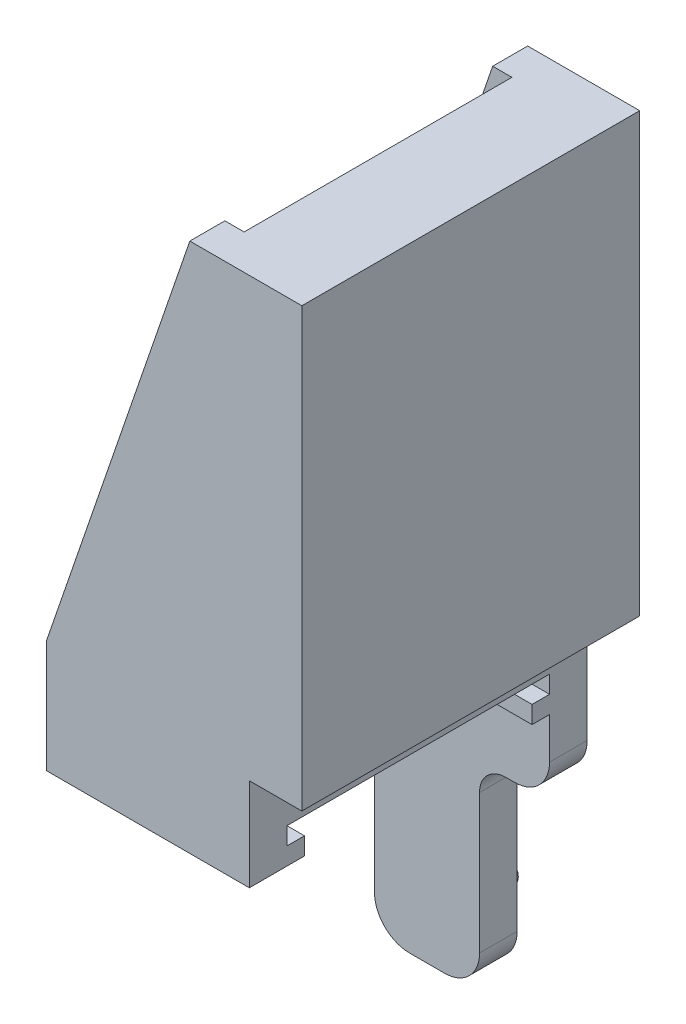
from build123d import *

# Parameters (mm, degrees)
SALIENTE_EXTRUIR1_DEPTH = 19.3
CROQUIS2_W              = 15.3
CROQUIS2_H              = 26.3
CORTAR_EXTRUIR1_DEPTH   = 9.3
CORTAR_EXTRUIR2_DEPTH   = 12
CROQUIS5_R              = 0.75
SALIENTE_EXTRUIR2_DEPTH = 2
CROQUIS6_W              = 19.3
CROQUIS6_H              = 25
SALIENTE_EXTRUIR3_DEPTH = 3


with BuildPart() as part:
    # Croquis1 → Saliente-Extruir1 (new body)
    with BuildSketch(Plane.XY):
        with BuildLine():
            Line((5.8, 23.05), (2.4, 23.05))
            Line((2.4, 23.05), (-5.8, -0.85))
            Line((-5.8, -0.85), (-5.8, -10.609737321))
            ThreePointArc((-5.8, -10.609737321), (-5.505459406, -11.318487649), (-4.795345946, -11.609726491))
            Line((-4.795345946, -11.609726491), (-4.702327027, -11.609293571))
            ThreePointArc((-4.702327027, -11.609293571), (-4.347270297, -11.754912992), (-4.2, -12.109288156))
            Line((-4.2, -12.109288156), (-4.2, -21.05))
            ThreePointArc((-4.2, -21.05), (-3.614213562, -22.464213562), (-2.2, -23.05))
            Line((-2.2, -23.05), (-0.2, -23.05))
            ThreePointArc((-0.2, -23.05), (1.214213562, -22.464213562), (1.8, -21.05))
            Line((1.8, -21.05), (1.8, -13.106955688))
            ThreePointArc((1.8, -13.106955688), (2.239339828, -12.046295517), (3.3, -11.606955688))
            Line((3.3, -11.606955688), (3.8, -11.606955688))
            ThreePointArc((3.8, -11.606955688), (5.214213562, -11.021169251), (5.8, -9.606955688))
            Line((5.8, -9.606955688), (5.8, 23.05))
        make_face()
    extrude(amount=SALIENTE_EXTRUIR1_DEPTH)

    # Croquis2 → Cortar-Extruir1 (cut)
    with BuildSketch(Plane.ZY.offset(5.8)):
        with Locations((9.65, 9.9)):
            Rectangle(CROQUIS2_W, CROQUIS2_H)
    extrude(amount=-CORTAR_EXTRUIR1_DEPTH, mode=Mode.SUBTRACT)

    # Croquis4 → Cortar-Extruir2 (cut)
    with BuildSketch(Plane.ZY.offset(5.8)):
        Polygon((2.15, -5.25), (2.15, -6.25), (3.15, -6.25), (3.15, -7.25), (2.15, -7.25), (2.15, -23.25), (19.55, -23.25), (19.55, -7.25), (16.15, -7.25), (16.15, -6.25), (17.15, -6.25), (17.15, -5.25), align=None)
    extrude(amount=-CORTAR_EXTRUIR2_DEPTH, mode=Mode.SUBTRACT)

    # Croquis5 → Saliente-Extruir2 (add)
    with BuildSketch(Plane(origin=(0, 0, 0), x_dir=(-1, 0, 0), z_dir=(0, 0, -1))):
        with Locations((0.885806677, -20.318206006)):
            Circle(CROQUIS5_R)
    extrude(amount=SALIENTE_EXTRUIR2_DEPTH)

    # Croquis6 → Saliente-Extruir3 (add)
    with BuildSketch(Plane(origin=(5.8, 0, 0), x_dir=(0, 0, -1), z_dir=(1, 0, 0))):
        with Locations((-9.65, 10.55)):
            Rectangle(CROQUIS6_W, CROQUIS6_H)
    extrude(amount=SALIENTE_EXTRUIR3_DEPTH)


solid = part.part
